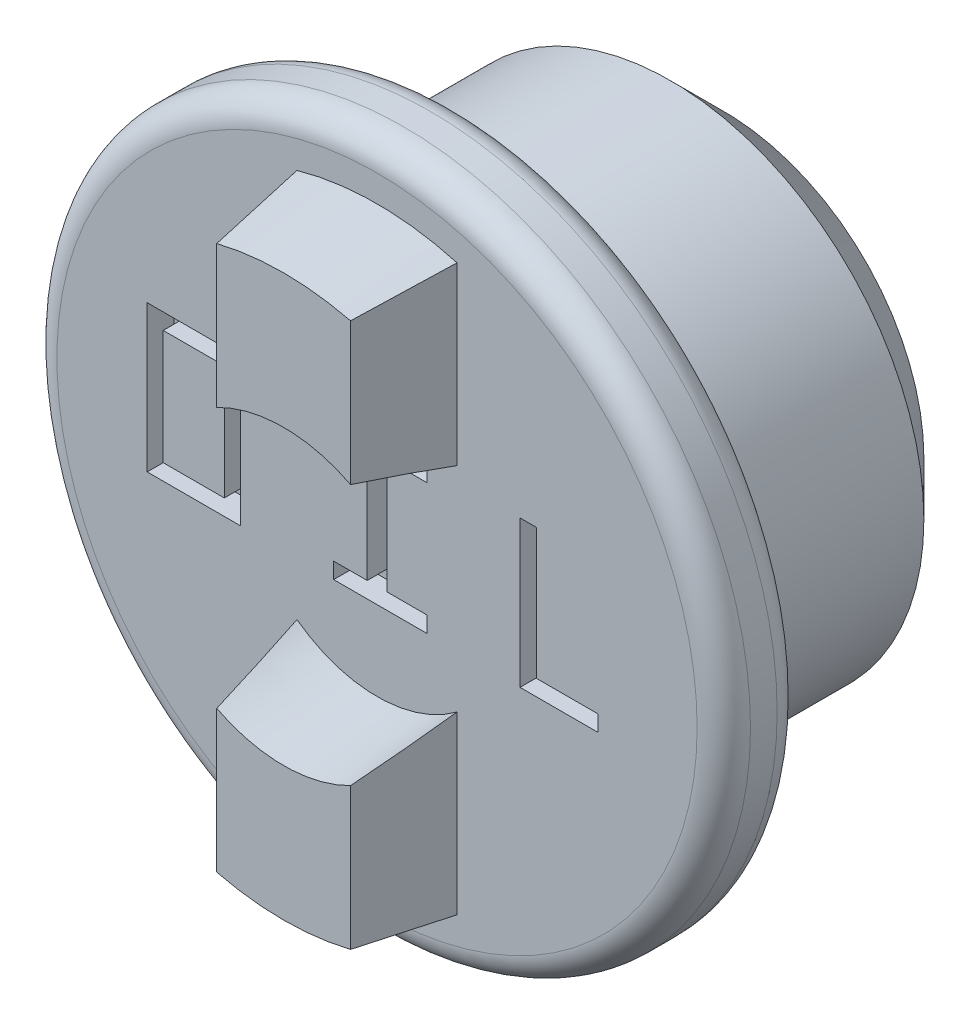
from build123d import *

# Parameters (mm, degrees)
SKETCH1_R           = 9.5
BOSS_EXTRUDE1_DEPTH = 10
CHAMFER1_SIZE       = 2
SKETCH2_R           = 13
BOSS_EXTRUDE2_DEPTH = 3
BOSS_EXTRUDE3_DEPTH = 3.5
BOSS_EXTRUDE3_TAPER = 8
FILLET1_R           = 1
SKETCH3_W           = 2.290416552
SKETCH3_H           = 4.294163917
CUT_EXTRUDE1_DEPTH  = 1


with BuildPart() as part:
    # Sketch1 → Boss-Extrude1 (new body)
    with BuildSketch(Plane.XY):
        Circle(SKETCH1_R)
    extrude(amount=BOSS_EXTRUDE1_DEPTH)

    # Chamfer1
    chamfer1_edges = [part.edges().sort_by_distance(p)[0] for p in [
        (-9.5, 0, 0),
    ]]
    chamfer(chamfer1_edges, length=CHAMFER1_SIZE)

    # Sketch2 → Boss-Extrude2 (add)
    with BuildSketch(Plane.XY.offset(10)):
        Circle(SKETCH2_R)
    extrude(amount=BOSS_EXTRUDE2_DEPTH)

    # Sketch4 → Boss-Extrude3 (add)
    with BuildSketch(Plane.XY.offset(13)):
        with BuildLine():
            ThreePointArc((3, 10.583005244), (0, 11), (-3, 10.583005244))
            Line((-3, 10.583005244), (-3, 4))
            ThreePointArc((-3, 4), (0, 5), (3, 4))
            Line((3, 4), (3, 10.583005244))
        make_face()
        with BuildLine():
            ThreePointArc((3, -4), (0, -5), (-3, -4))
            Line((-3, -4), (-3, -10.583005244))
            ThreePointArc((-3, -10.583005244), (0, -11), (3, -10.583005244))
            Line((3, -10.583005244), (3, -4))
        make_face()
    extrude(amount=BOSS_EXTRUDE3_DEPTH, taper=BOSS_EXTRUDE3_TAPER)

    # Fillet1
    fillet1_edges = [part.edges().sort_by_distance(p)[0] for p in [
        (-13, 0, 10),
        (-13, 0, 13),
    ]]
    fillet(fillet1_edges, radius=FILLET1_R)

    # Sketch3 → Cut-Extrude1 (cut)
    with BuildSketch(Plane.XY.offset(13)):
        Polygon((-1.625120105, -2.013905208), (-1.625120105, -1.413905208), (-0.367640206, -1.413905208), (-0.367640206, 2.880258709), (-1.625120105, 2.880258709), (-1.625120105, 3.480258709), (1.874879895, 3.480258709), (1.874879895, 2.880258709), (0.367640206, 2.880258709), (0.367640206, -1.413905208), (1.874879895, -1.413905208), (1.874879895, -2.013905208), align=None)
        Polygon((5.359789492, 3.480258709), (5.359789492, -1.419741291), (5.359789492, -2.019741291), (8.274879895, -2.019741291), (8.274879895, -1.419741291), (5.974879895, -1.419741291), (5.974879895, 3.480258709), align=None)
        Polygon((-8.615536657, 3.480258709), (-8.615536657, -2.013905208), (-5.125120105, -2.013905208), (-5.125120105, 2.880258709), (-5.125120105, 3.480258709), align=None)
        with Locations((-6.870328381, 0.73317675)):
            Rectangle(SKETCH3_W, SKETCH3_H, mode=Mode.SUBTRACT)
    extrude(amount=-CUT_EXTRUDE1_DEPTH, mode=Mode.SUBTRACT)


solid = part.part
